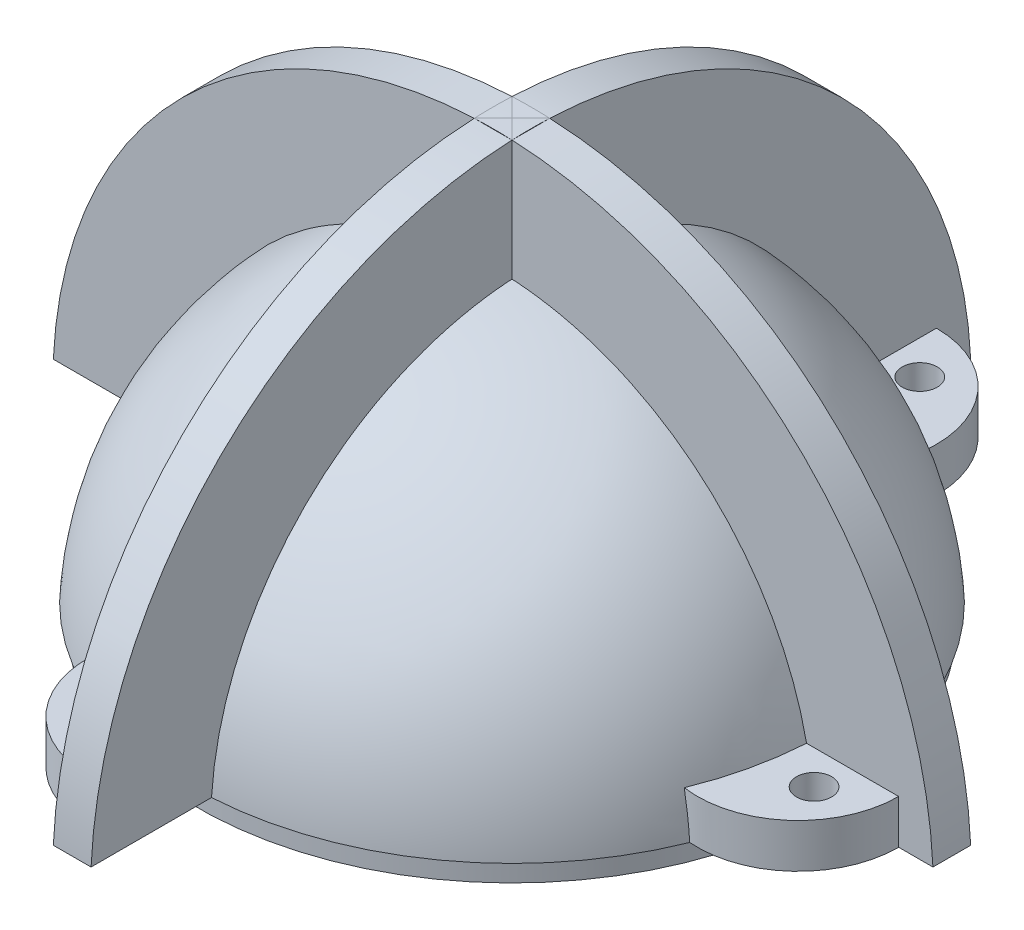
from build123d import *

# Parameters (mm, degrees)
BOSS_EXTRUDE1_DEPTH      = 1.5
BOSS_EXTRUDE1_DEPTH_BACK = 1.5
BOSS_EXTRUDE2_DEPTH      = 1.5
BOSS_EXTRUDE2_DEPTH_BACK = 1.5
SKETCH4_W                = 11.052180397
SKETCH4_H                = 1.65
SKETCH5_R                = 1.4
BOSS_EXTRUDE20_DEPTH     = 3.5
SKETCH6_R                = 26
SKETCH6_R_2              = 25
CUT_EXTRUDE1_DEPTH       = 1.65


with BuildPart() as part:
    # Sketch1 → Revolve1 (revolve)
    with BuildSketch(Plane.XY):
        with BuildLine():
            Line((-20.885, 0), (-20.885, 11.793939121))
            ThreePointArc((-20.885, 11.793939121), (-12.091372858, 20.714220415), (0, 23.985))
            Line((0, 23.985), (0, 25.485))
            ThreePointArc((0, 25.485), (-18.020616319, 18.020616319), (-25.485, 0))
            Line((-25.485, 0), (-24.285, 0))
            Line((-24.285, 0), (-24.285, 0.5))
            Line((-24.285, 0.5), (-22.085, 0.5))
            Line((-22.085, 0.5), (-22.085, 0))
            Line((-22.085, 0), (-20.885, 0))
        make_face()
    revolve(axis=Axis((0, 0, 0), (0, 1, 0)))



with BuildPart() as body_2:
    # Sketch2 → Boss-Extrude1 (new body, two sides)
    with BuildSketch(Plane.XY) as boss_extrude1_sk:
        with BuildLine():
            Line((-24.9, 0), (-35, 0))
            ThreePointArc((-35, 0), (0, 35), (35, 0))
            Line((35, 0), (24.9, 0))
            ThreePointArc((24.9, 0), (0, 24.9), (-24.9, 0))
        make_face()
    extrude(amount=BOSS_EXTRUDE1_DEPTH)
    extrude(boss_extrude1_sk.sketch, amount=-BOSS_EXTRUDE1_DEPTH_BACK)

    # Sketch3 → Boss-Extrude2 (add, two sides)
    with BuildSketch(Plane(origin=(0, 0, 0), x_dir=(0, 0, -1), z_dir=(1, 0, 0))) as boss_extrude2_sk:
        with BuildLine():
            Line((35, 0), (24.9, 0))
            ThreePointArc((24.9, 0), (0, 24.9), (-24.9, 0))
            Line((-24.9, 0), (-35, 0))
            ThreePointArc((-35, 0), (0, 35), (35, 0))
        make_face()
    extrude(amount=BOSS_EXTRUDE2_DEPTH)
    extrude(boss_extrude2_sk.sketch, amount=-BOSS_EXTRUDE2_DEPTH_BACK)

    # Sketch4 → Cut-Revolve2 (revolve, cut)
    with BuildSketch(Plane.XY):
        with Locations((-30.371361379, 0.825)):
            Rectangle(SKETCH4_W, SKETCH4_H)
    revolve(axis=Axis((0, 0, 0), (0, 1, 0)), mode=Mode.SUBTRACT)


with BuildPart() as part_1:
    add(part.part)

    add(body_2.part)  # Boss-Extrude20 merges body 2
    # Sketch5 → Boss-Extrude20 (add)
    with BuildSketch(Plane.XZ.offset(-1.65)):
        with BuildLine():
            Line((-32.23863084, -1.5), (-24.23863084, -1.5))
            ThreePointArc((-24.23863084, -1.5), (-23.660511509, -5.471875377), (-22.4360777, -9.294280094))
            ThreePointArc((-22.4360777, -9.294280094), (-27.026694315, -8.998446643), (-30.695451754, -6.223289498))
            ThreePointArc((-30.695451754, -6.223289498), (-31.843056108, -3.984495189), (-32.23863084, -1.5))
        make_face()
        with Locations((-28.212839525, -4.2)):
            Circle(SKETCH5_R, mode=Mode.SUBTRACT)
        with BuildLine():
            Line((24.23863084, 1.5), (32.23863084, 1.5))
            ThreePointArc((32.23863084, 1.5), (31.843056108, 3.984495189), (30.695451754, 6.223289498))
            ThreePointArc((30.695451754, 6.223289498), (27.026694315, 8.998446643), (22.4360777, 9.294280094))
            ThreePointArc((22.4360777, 9.294280094), (23.660511509, 5.471875377), (24.23863084, 1.5))
        make_face()
        with Locations((28.212839525, 4.2)):
            Circle(SKETCH5_R, mode=Mode.SUBTRACT)
        with BuildLine():
            Line((-1.5, 32.23863084), (-1.5, 24.23863084))
            ThreePointArc((-1.5, 24.23863084), (-5.471875377, 23.660511509), (-9.294280094, 22.4360777))
            ThreePointArc((-9.294280094, 22.4360777), (-8.998446643, 27.026694315), (-6.223289498, 30.695451754))
            ThreePointArc((-6.223289498, 30.695451754), (-3.984495189, 31.843056108), (-1.5, 32.23863084))
        make_face()
        with Locations((-4.2, 28.212839525)):
            Circle(SKETCH5_R, mode=Mode.SUBTRACT)
        with BuildLine():
            Line((1.5, -32.23863084), (1.5, -24.23863084))
            ThreePointArc((1.5, -24.23863084), (5.471875377, -23.660511509), (9.294280094, -22.4360777))
            ThreePointArc((9.294280094, -22.4360777), (8.998446643, -27.026694315), (6.223289498, -30.695451754))
            ThreePointArc((6.223289498, -30.695451754), (3.984495189, -31.843056108), (1.5, -32.23863084))
        make_face()
        with Locations((4.2, -28.212839525)):
            Circle(SKETCH5_R, mode=Mode.SUBTRACT)
    extrude(amount=-BOSS_EXTRUDE20_DEPTH)

    # Sketch6 → Cut-Extrude1 (cut)
    with BuildSketch(Plane.XZ):
        Circle(SKETCH6_R)
        Circle(SKETCH6_R_2, mode=Mode.SUBTRACT)
    extrude(amount=-CUT_EXTRUDE1_DEPTH, mode=Mode.SUBTRACT)


solid = part_1.part
